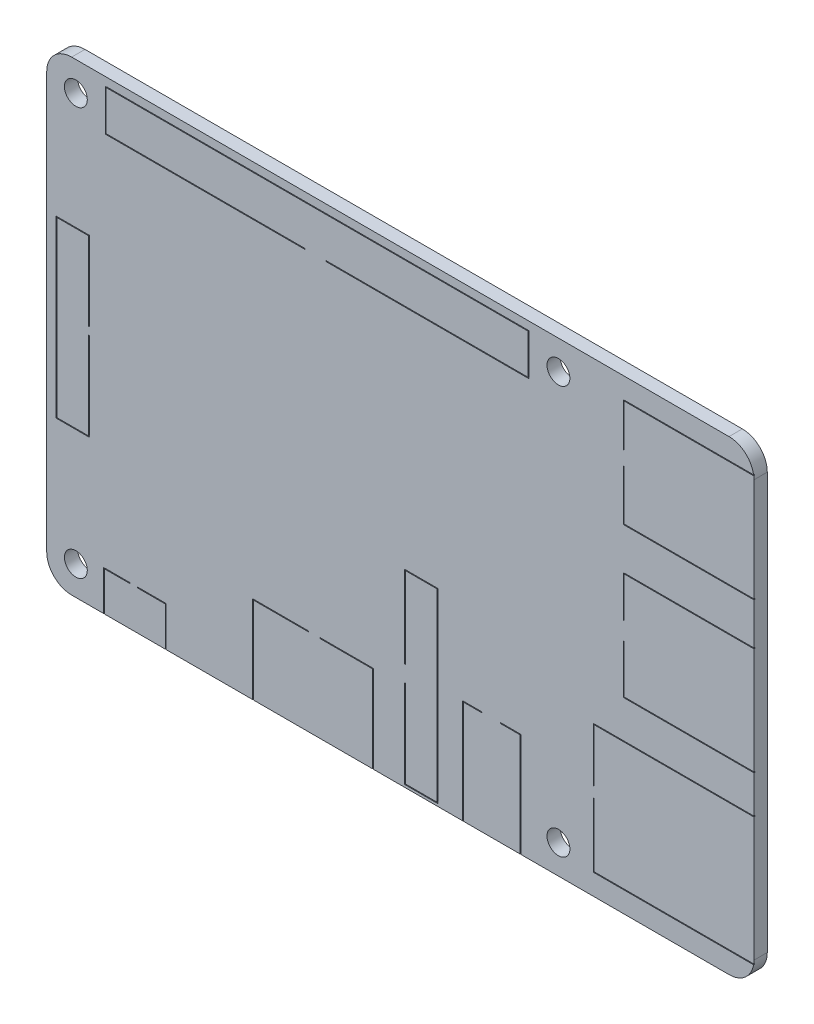
from build123d import *

# Parameters (mm, degrees)
SKETCH1_R           = 1.375
BOSS_EXTRUDE1_DEPTH = 1.6
CUT_EXTRUDE1_DEPTH  = 0.1


with BuildPart() as part:
    # Sketch1 → Boss-Extrude1 (new body)
    with BuildSketch(Plane.XY):
        with BuildLine():
            Line((-39.5, -28), (39.5, -28))
            ThreePointArc((39.5, -28), (41.621320344, -27.121320344), (42.5, -25))
            Line((42.5, -25), (42.5, 25))
            ThreePointArc((42.5, 25), (41.621320344, 27.121320344), (39.5, 28))
            Line((39.5, 28), (-39.5, 28))
            ThreePointArc((-39.5, 28), (-41.621320344, 27.121320344), (-42.5, 25))
            Line((-42.5, 25), (-42.5, -25))
            ThreePointArc((-42.5, -25), (-41.621320344, -27.121320344), (-39.5, -28))
        make_face()
        with Locations((-39, 24.5)):
            Circle(SKETCH1_R, mode=Mode.SUBTRACT)
        with Locations((-39, -24.5)):
            Circle(SKETCH1_R, mode=Mode.SUBTRACT)
        with Locations((19, 24.5)):
            Circle(SKETCH1_R, mode=Mode.SUBTRACT)
        with Locations((19, -24.5)):
            Circle(SKETCH1_R, mode=Mode.SUBTRACT)
    extrude(amount=BOSS_EXTRUDE1_DEPTH)

    # Sketch2 → Cut-Extrude1 (cut)
    with BuildSketch(Plane.XY.offset(1.6)):
        Polygon((-35.65, -28.636850855), (-28.15, -28.636850855), (-28.15, -23.2), (-31.573707352, -23.2), (-31.573707352, -23.3), (-28.25, -23.3), (-28.25, -28.536850855), (-35.55, -28.536850855), (-35.55, -23.3), (-32.465045999, -23.3), (-32.465045999, -23.2), (-35.65, -23.2), align=None)
        Polygon((-17.75, -17.5), (-11.015830732, -17.5), (-11.015830732, -17.6), (-17.65, -17.6), (-17.65, -33.061376344), (-3.35, -33.061376344), (-3.35, -17.6), (-9.684859924, -17.6), (-9.684859924, -17.5), (-3.25, -17.5), (-3.25, -33.161376344), (-17.75, -33.161376344), align=None)
        Polygon((0.5, -5.3), (4.5, -5.3), (4.5, -27.7), (0.5, -27.7), (0.5, -17.125), (0.6, -17.125), (0.6, -27.6), (4.4, -27.6), (4.4, -5.4), (0.6, -5.4), (0.6, -15.17398131), (0.5, -15.17398131), align=None)
        Polygon((7.5, -15.5), (9.799158316, -15.5), (9.799158316, -15.6), (7.6, -15.6), (7.6, -31.061376344), (14.4, -31.061376344), (14.4, -15.6), (12.062610562, -15.6), (12.062610562, -15.5), (14.5, -15.5), (14.5, -31.161376344), (7.5, -31.161376344), align=None)
        Polygon((-35.45, 27), (15.45, 27), (15.45, 22), (-8.906687942, 22), (-8.906687942, 22.1), (15.35, 22.1), (15.35, 26.9), (-35.35, 26.9), (-35.35, 22.1), (-11.458179647, 22.1), (-11.458179647, 22), (-35.45, 22), align=None)
        Polygon((-41.371710411, -10.514157593), (-37.371710411, -10.514157593), (-37.371710411, 0.094714316), (-37.471710411, 0.094714316), (-37.471710411, -10.414157593), (-41.271710411, -10.414157593), (-41.271710411, 10.414157593), (-37.471710411, 10.414157593), (-37.471710411, 1), (-37.371710411, 1), (-37.371710411, 10.514157593), (-41.371710411, 10.514157593), align=None)
        Polygon((23.2, -25.5), (44.7, -25.5), (44.7, -10), (23.2, -10), (23.2, -16.5), (23.3, -16.5), (23.3, -10.1), (44.6, -10.1), (44.6, -25.4), (23.3, -25.4), (23.3, -17.75), (23.2, -17.75), align=None)
        Polygon((26.8, -5.5), (54.071370237, -5.5), (54.071370237, 7.5), (26.8, 7.5), (26.8, 2.552788505), (26.9, 2.552788505), (26.9, 7.4), (53.971370237, 7.4), (53.971370237, -5.4), (26.9, -5.4), (26.9, 0.407211154), (26.8, 0.407211154), align=None)
        Polygon((26.8, 12.5), (57.71374017, 12.5), (57.71374017, 25.5), (26.8, 25.5), (26.8, 20.277341759), (26.9, 20.277341759), (26.9, 25.4), (57.61374017, 25.4), (57.61374017, 12.6), (26.9, 12.6), (26.9, 18.611308355), (26.8, 18.611308355), align=None)
    extrude(amount=-CUT_EXTRUDE1_DEPTH, mode=Mode.SUBTRACT)


solid = part.part
